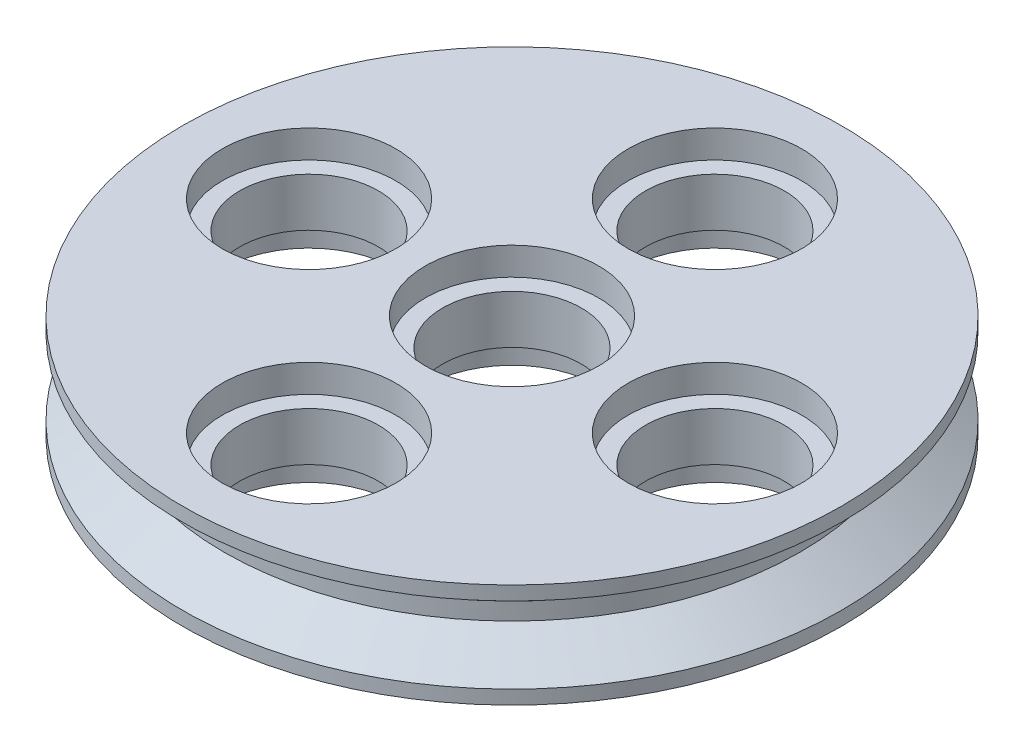
from build123d import *

# Parameters (mm, degrees)
HOLE1_D           = 4
HOLE1_DEPTH       = 1.5
HOLE1_CBORE_D     = 5
HOLE1_CBORE_DEPTH = 0.8
HOLE1_TIP         = 1.201721238


with BuildPart() as part:
    # Sketch2 → Revolve1 (revolve)
    with BuildSketch(Plane.XY):
        Polygon((9.5, 0.75), (9.5, 0.35), (8.300666852, -0.5), (8.300666852, -0.75), (0, -0.75), (0, 0.75), align=None)
    revolve(axis=Axis((0, 0.75, 0), (0, -1, 0)))

    # Hole1
    with Locations(Plane(origin=(0, 0.75, 0), x_dir=(1, 0, 0), z_dir=(0, 1, 0))):
        with Locations((0, 0), (-5.85, 0), (5.85, 0), (0, 5.85), (0, -5.85)):
            CounterBoreHole(HOLE1_D / 2, HOLE1_CBORE_D / 2, HOLE1_CBORE_DEPTH, depth=HOLE1_DEPTH)
            with Locations((0, 0, -(HOLE1_DEPTH + HOLE1_TIP / 2))):  # 118° drill point
                Cone(0, HOLE1_D / 2, HOLE1_TIP, mode=Mode.SUBTRACT)

    # Mirror1: part across plane


with BuildPart() as part_1:
    add(part.part)
    add(part.part.mirror(Plane.ZX.offset(-0.75)))


solid = part_1.part
